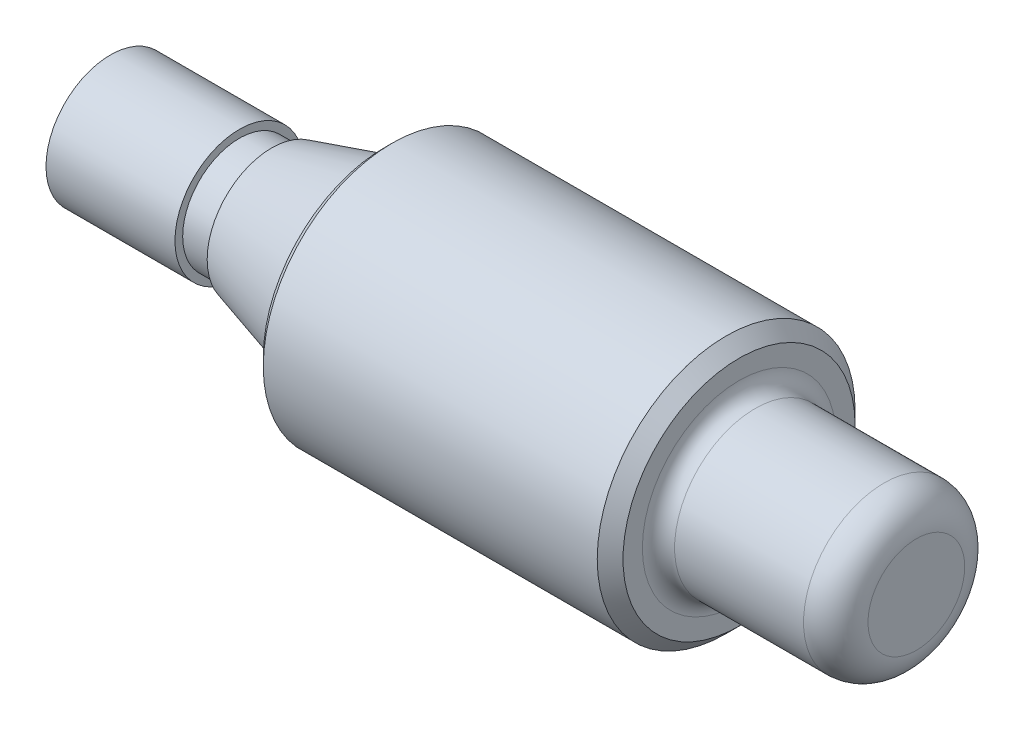
from build123d import *

# Parameters (mm, degrees)
BOSS_EXTRUDE1_DEPTH      = 39.6875
BOSS_EXTRUDE1_DEPTH_BACK = 39.6875
SKETCH2_R                = 12.7
SKETCH3_OUTSIDE_W        = 44.824
SKETCH3_OUTSIDE_H        = 44.824
SKETCH3_OUTSIDE_R        = 7.9375
CUT_EXTRUDE1_DEPTH       = 17.4625
FILLET1_R                = 3.175
FILLET2_R                = 1.5875
CHAMFER1_SIZE            = 1.27
SKETCH4_OUTSIDE_W        = 44.824
SKETCH4_OUTSIDE_H        = 44.824
SKETCH4_OUTSIDE_R        = 6.35
CUT_EXTRUDE2_DEPTH       = 12.7
SKETCH6_OUTSIDE_W        = 44.824
SKETCH6_OUTSIDE_H        = 44.824
SKETCH6_OUTSIDE_R        = 5.588
CUT_EXTRUDE3_DEPTH       = 3.175
FILLET3_R                = 1.27
CHAMFER2_SIZE            = 0.762


with BuildPart() as part:
    # Sketch2 → Boss-Extrude1 (new, two sides: drawn at the far end of the back side and taken through both)
    with BuildSketch(Plane(origin=(0, 0, 0), x_dir=(0, 0, -1), z_dir=(1, 0, 0)).offset(-BOSS_EXTRUDE1_DEPTH_BACK)):
        Circle(SKETCH2_R)
    extrude(amount=BOSS_EXTRUDE1_DEPTH + BOSS_EXTRUDE1_DEPTH_BACK)

    # Sketch3 outside → Cut-Extrude1 (cut)
    with BuildSketch(Plane(origin=(39.6875, 0, 0), x_dir=(0, 0, -1), z_dir=(1, 0, 0))):
        Rectangle(SKETCH3_OUTSIDE_W, SKETCH3_OUTSIDE_H)
        Circle(SKETCH3_OUTSIDE_R, mode=Mode.SUBTRACT)
    extrude(amount=-CUT_EXTRUDE1_DEPTH, mode=Mode.SUBTRACT)

    # Fillet1
    fillet1_edges = [part.edges().sort_by_distance(p)[0] for p in [
        (39.6875, 0, 7.9375),
    ]]
    fillet(fillet1_edges, radius=FILLET1_R)

    # Fillet2
    fillet2_edges = [part.edges().sort_by_distance(p)[0] for p in [
        (22.225, 0, 7.9375),
    ]]
    fillet(fillet2_edges, radius=FILLET2_R)

    # Chamfer1
    chamfer1_edges = [part.edges().sort_by_distance(p)[0] for p in [
        (22.225, 0, 12.7),
    ]]
    chamfer(chamfer1_edges, length=CHAMFER1_SIZE)

    # Sketch4 outside → Cut-Extrude2 (cut)
    with BuildSketch(Plane.ZY.offset(39.6875)):
        Rectangle(SKETCH4_OUTSIDE_W, SKETCH4_OUTSIDE_H)
        Circle(SKETCH4_OUTSIDE_R, mode=Mode.SUBTRACT)
    extrude(amount=-CUT_EXTRUDE2_DEPTH, mode=Mode.SUBTRACT)

    # Sketch6 outside → Cut-Extrude3 (cut)
    with BuildSketch(Plane.ZY.offset(26.9875)):
        Rectangle(SKETCH6_OUTSIDE_W, SKETCH6_OUTSIDE_H)
        Circle(SKETCH6_OUTSIDE_R, mode=Mode.SUBTRACT)
    extrude(amount=-CUT_EXTRUDE3_DEPTH, mode=Mode.SUBTRACT)

    # Sketch13 → Cut-Revolve1 (revolve, cut)
    with BuildSketch(Plane.XY):
        Polygon((-23.8125, 6.35), (-12.7, 9.525), (-12.7, 12.7), (-23.8125, 12.7), align=None)
    revolve(axis=Axis((-43.65625, 0, 0), (1, 0, 0)), mode=Mode.SUBTRACT)

    # Fillet3
    fillet3_edges = [part.edges().sort_by_distance(p)[0] for p in [
        (-12.7, -9.525, 0),
    ]]
    fillet(fillet3_edges, radius=FILLET3_R)

    # Chamfer2
    chamfer2_edges = [part.edges().sort_by_distance(p)[0] for p in [
        (-12.7, 0, 12.7),
    ]]
    chamfer(chamfer2_edges, length=CHAMFER2_SIZE)


solid = part.part
